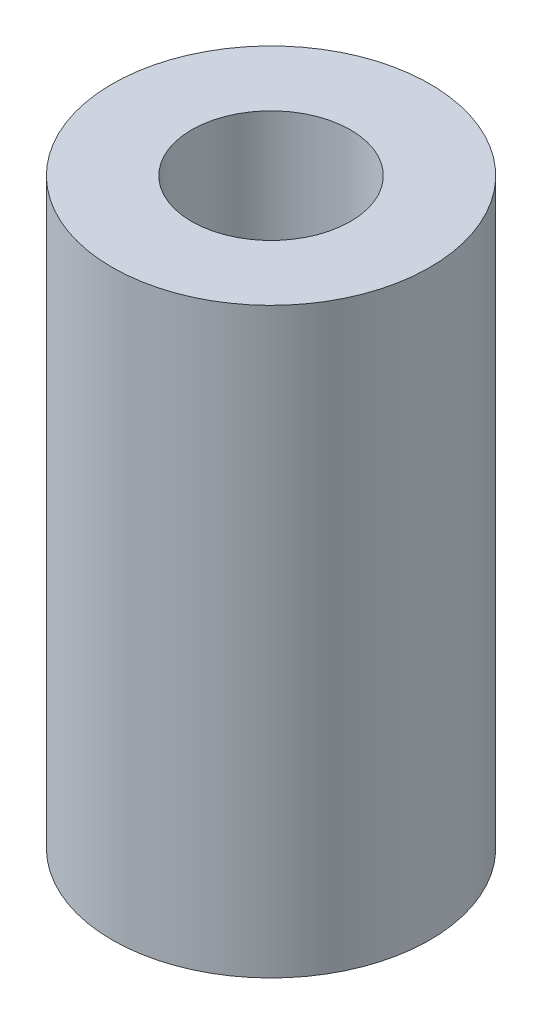
from build123d import *

# Parameters (mm, degrees)
ESQUISSE1_R             = 6
BOSS_EXTRU_1_DEPTH      = 22
ESQUISSE3_R             = 3
ENL_V_MAT_EXTRU_3_DEPTH = 22


with BuildPart() as part:
    # Esquisse1 → Boss.-Extru.1 (new body)
    with BuildSketch(Plane(origin=(0, 0, 0), x_dir=(1, 0, 0), z_dir=(0, 1, 0))):
        with Locations(Location((0, 0, 0), (0, 0, 270))):  # turned: the seam where the file's is
            Circle(ESQUISSE1_R)
    extrude(amount=BOSS_EXTRU_1_DEPTH)

    # Esquisse3 → Enlèv. mat.-Extru.3 (cut)
    with BuildSketch(Plane(origin=(0, 22, 0), x_dir=(1, 0, 0), z_dir=(0, 1, 0))):
        with Locations(Location((0, 0, 0), (0, 0, 270))):  # turned: the seam where the file's is
            Circle(ESQUISSE3_R)
    extrude(amount=-ENL_V_MAT_EXTRU_3_DEPTH, mode=Mode.SUBTRACT)


solid = part.part
